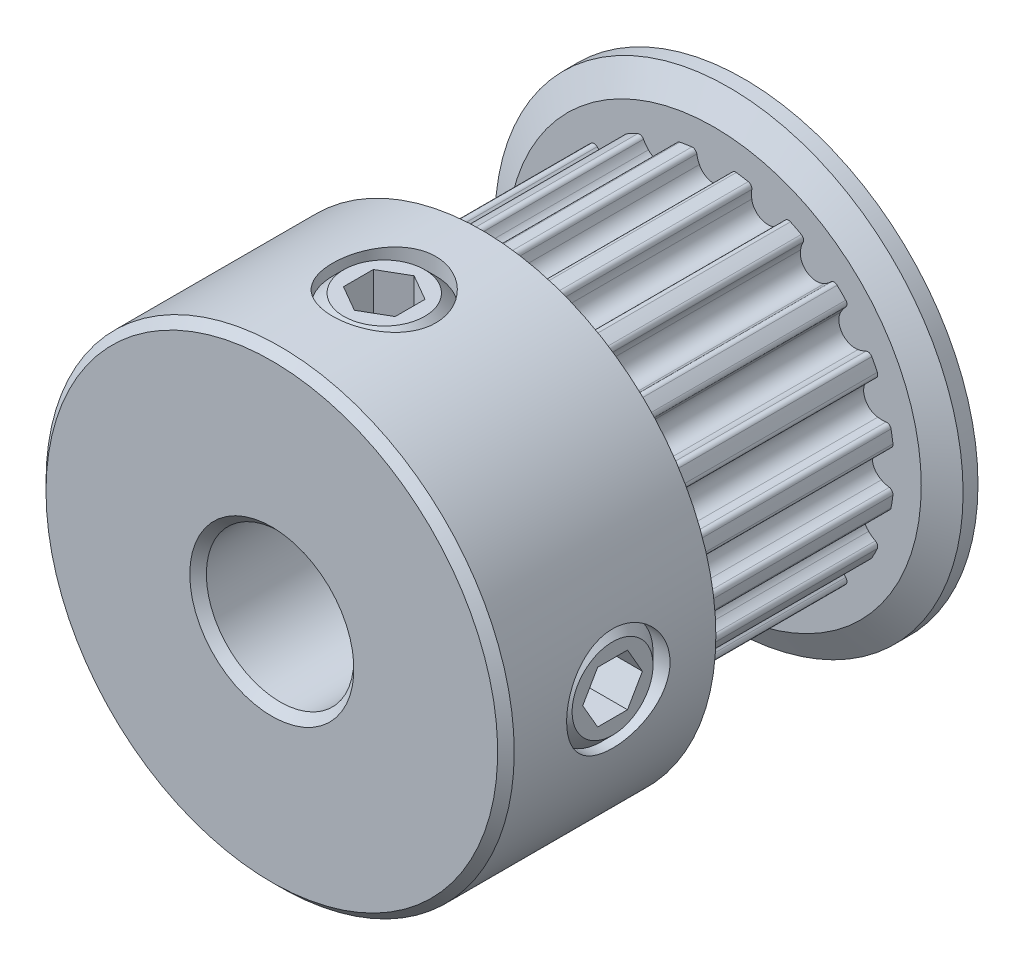
from build123d import *

# Parameters (mm, degrees)
CUT_EXTRUDE1_START = 0.38
CUT_EXTRUDE1_DEPTH = 7.37
CIRPATTERN1_COUNT  = 20
SKETCH4_R          = 1.7526
CUT_EXTRUDE2_DEPTH = 14.781453116
CUT_EXTRUDE3_DEPTH = 1.31445
CIRPATTERN3_COUNT  = 2
CIRPATTERN3_ANGLE  = 90
CHAMFER1_SIZE      = 0.28075


with BuildPart() as part:
    # Sketch2 → Revolve1 (revolve)
    with BuildSketch(Plane(origin=(0, 0, 0), x_dir=(0, 0, -1), z_dir=(1, 0, 0)), mode=Mode.PRIVATE) as revolve1_sk:
        Polygon((-8, 2.5), (8, 2.5), (8, 7.935), (7.495, 7.935), (6.99, 7.02175), (6.99, 6.1085), (-0.38, 6.1085), (-0.38, 7.02175), (-0.885, 7.935), (-8, 7.935), align=None)
    revolve(revolve1_sk.sketch.rotate(Axis((0, 0, 8), (0, 0, -1)), 90), axis=Axis((0, 0, 8), (0, 0, -1)))

    # Sketch3 → Cut-Extrude1 (cut)
    with BuildSketch(Plane.XY.offset(CUT_EXTRUDE1_START)):
        with BuildLine():
            Line((2.59132747, 7.935), (-2.59132747, 7.935))
            Line((-2.59132747, 7.935), (-1.896292335, 5.806707124))
            ThreePointArc((-1.896292335, 5.806707124), (-1.330166224, 5.961914966), (-0.751756185, 6.062065233))
            ThreePointArc((-0.751756185, 6.062065233), (-0.643911332, 6.033664451), (-0.58547487, 5.93867868))
            ThreePointArc((-0.58547487, 5.93867868), (-0.551683777, 5.801420225), (-0.498876404, 5.670297753))
            ThreePointArc((-0.498876404, 5.670297753), (0, 5.3585), (0.498876404, 5.670297753))
            ThreePointArc((0.498876404, 5.670297753), (0.551683777, 5.801420225), (0.58547487, 5.93867868))
            ThreePointArc((0.58547487, 5.93867868), (0.643911332, 6.033664451), (0.751756185, 6.062065233))
            ThreePointArc((0.751756185, 6.062065233), (1.330166224, 5.961914966), (1.896292335, 5.806707124))
            Line((1.896292335, 5.806707124), (2.59132747, 7.935))
        make_face()
    cut_extrude1 = extrude(amount=-CUT_EXTRUDE1_DEPTH, mode=Mode.SUBTRACT)

    # CirPattern1: Cut-Extrude1 ×20 about axis
    cirpattern1_axis = Axis((0, 0, 0), (0, 0, 1))
    for i in range(1, CIRPATTERN1_COUNT):
        add(cut_extrude1.rotate(cirpattern1_axis, i * 360 / CIRPATTERN1_COUNT), mode=Mode.SUBTRACT)

    # Sketch4 → Cut-Extrude2 (cut, through all)
    with BuildSketch(Plane(origin=(0, 0, 0), x_dir=(0, -1, 0), z_dir=(1, 0, 0))):
        with Locations(Location((0, -4.19, 0), (0, 0, 270))):
            Circle(SKETCH4_R)
    cut_extrude2 = extrude(amount=CUT_EXTRUDE2_DEPTH, mode=Mode.SUBTRACT)

    # Sketch5 → Revolve2 (revolve)
    with BuildSketch(Plane.XY.offset(4.19), mode=Mode.PRIVATE) as revolve2_sk:
        Polygon((2.5, -1.3716), (2.5, 0), (7.739032126, 0), (7.739032126, -1.3716), (7.358032126, -1.7526), (2.881, -1.7526), align=None)
    revolve2 = revolve(revolve2_sk.sketch.rotate(Axis((2.5, 0, 4.19), (1, 0, 0)), 270), axis=Axis((2.5, 0, 4.19), (1, 0, 0)))

    # Sketch6 → Cut-Extrude3 (cut)
    with BuildSketch(Plane(origin=(7.739032126, 5.384140679, 0), x_dir=(0, -1, 0), z_dir=(-1, 0, 0))):
        Polygon((5.384140679, 5.201864082), (4.507840679, 4.695932041), (4.507840679, 3.684067959), (5.384140679, 3.178135918), (6.260440679, 3.684067959), (6.260440679, 4.695932041), align=None)
    cut_extrude3 = extrude(amount=CUT_EXTRUDE3_DEPTH, mode=Mode.SUBTRACT)

    # CirPattern3: Cut-Extrude2, Revolve2, Cut-Extrude3 ×2 about axis
    cirpattern3_axis = Axis((0, 0, 0), (0, 0, 1))
    add([cut_extrude2.rotate(cirpattern3_axis, i * CIRPATTERN3_ANGLE / (CIRPATTERN3_COUNT - 1)) for i in range(1, CIRPATTERN3_COUNT)], mode=Mode.SUBTRACT)
    add([revolve2.rotate(cirpattern3_axis, i * CIRPATTERN3_ANGLE / (CIRPATTERN3_COUNT - 1)) for i in range(1, CIRPATTERN3_COUNT)])
    add([cut_extrude3.rotate(cirpattern3_axis, i * CIRPATTERN3_ANGLE / (CIRPATTERN3_COUNT - 1)) for i in range(1, CIRPATTERN3_COUNT)], mode=Mode.SUBTRACT)

    # Chamfer1
    chamfer1_edges = [part.edges().sort_by_distance(p)[0] for p in [
        (-2.5, 0, 8),
        (-7.935, 0, 8),
    ]]
    chamfer(chamfer1_edges, length=CHAMFER1_SIZE)


solid = part.part
